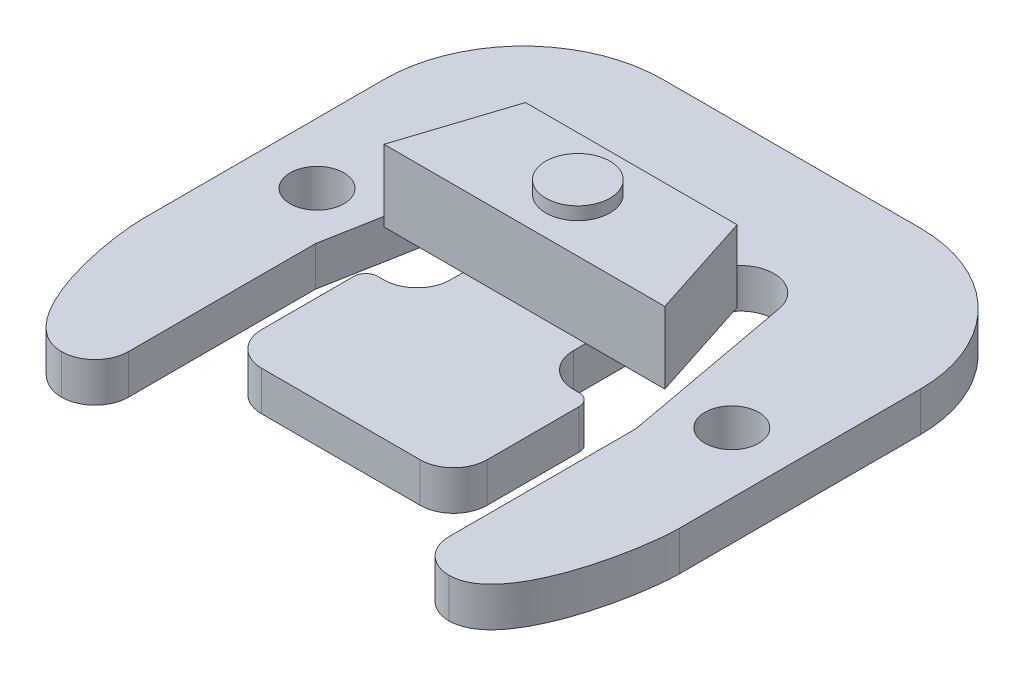
from build123d import *

# Parameters (mm, degrees)
SKETCH1_R           = 1.7018
BOSS_EXTRUDE1_DEPTH = 2.5019
BOSS_EXTRUDE2_DEPTH = 4.5339
SKETCH3_R           = 2.032
BOSS_EXTRUDE3_DEPTH = 0.8128
SKETCH4_R           = 1.77918252
BOSS_EXTRUDE4_DEPTH = 1.0033


with BuildPart() as part:
    # Sketch1 → Boss-Extrude1 (new body)
    with BuildSketch(Plane(origin=(0, 0, 0), x_dir=(1, 0, 0), z_dir=(0, 1, 0))):
        with BuildLine():
            Line((27.1272, -31.8389), (27.1272, -19.9898))
            Line((27.1272, -19.9898), (25.072658108, -8.860571344))
            ThreePointArc((25.072658108, -8.860571344), (22.793680926, -7.133528849), (20.8661, -9.2456))
            Line((20.8661, -9.2456), (20.8661, -17.7038))
            ThreePointArc((20.8661, -17.7038), (21.487297228, -19.203502772), (22.987, -19.8247))
            Line((22.987, -19.8247), (23.3553, -19.8247))
            ThreePointArc((23.3553, -19.8247), (23.894115367, -20.047884633), (24.1173, -20.5867))
            Line((24.1173, -20.5867), (24.1173, -26.416))
            ThreePointArc((24.1173, -26.416), (23.496102772, -27.915702772), (21.9964, -28.5369))
            Line((21.9964, -28.5369), (11.9634, -28.5369))
            ThreePointArc((11.9634, -28.5369), (10.463697228, -27.915702772), (9.8425, -26.416))
            Line((9.8425, -26.416), (9.8425, -20.5867))
            ThreePointArc((9.8425, -20.5867), (10.065684633, -20.047884633), (10.6045, -19.8247))
            Line((10.6045, -19.8247), (10.9728, -19.8247))
            ThreePointArc((10.9728, -19.8247), (12.472502772, -19.203502772), (13.0937, -17.7038))
            Line((13.0937, -17.7038), (13.0937, -9.2456))
            ThreePointArc((13.0937, -9.2456), (11.166119074, -7.133528849), (8.887141892, -8.860571344))
            Line((8.887141892, -8.860571344), (6.8326, -19.9898))
            Line((6.8326, -19.9898), (6.8326, -31.8389))
            ThreePointArc((6.8326, -31.8389), (6.211402772, -33.338602772), (4.7117, -33.9598))
            add(Edge.make_bspline(
                [(0, -24.0873616), (0, -26.517133331), (1.36922065, -33.9598), (4.7117, -33.9598)],
                knots=[0, 0, 0, 0, 1, 1, 1, 1], degree=3))
            Line((0, -24.0873616), (0, -8.8138))
            ThreePointArc((0, -8.8138), (2.581502252, -2.581502252), (8.8138, 0))
            Line((8.8138, 0), (25.146, 0))
            ThreePointArc((25.146, 0), (31.378297748, -2.581502252), (33.9598, -8.8138))
            Line((33.9598, -8.8138), (33.9598, -24.0873616))
            add(Edge.make_bspline(
                [(33.9598, -24.0873616), (33.9598, -26.517133331), (32.59057935, -33.9598), (29.2481, -33.9598)],
                knots=[0, 0, 0, 0, 1, 1, 1, 1], degree=3))
            ThreePointArc((29.2481, -33.9598), (27.748397228, -33.338602772), (27.1272, -31.8389))
        make_face()
        with Locations((30.1117, -16.9164)):
            Circle(SKETCH1_R, mode=Mode.SUBTRACT)
        with Locations((3.8481, -16.9164)):
            Circle(SKETCH1_R, mode=Mode.SUBTRACT)
    extrude(amount=BOSS_EXTRUDE1_DEPTH)

    # Sketch2 → Boss-Extrude2 (add)
    with BuildSketch(Plane(origin=(0, 2.5019, 0), x_dir=(1, 0, 0), z_dir=(0, 1, 0))):
        Polygon((8.0899, -16.9164), (25.8699, -16.9164), (23.67915, -10.1473), (10.28065, -10.1473), align=None)
    extrude(amount=BOSS_EXTRUDE2_DEPTH)

    # Sketch3 → Boss-Extrude3 (add)
    with BuildSketch(Plane(origin=(0, 7.0358, 0), x_dir=(-1, 0, 0), z_dir=(0, 1, 0))):
        with Locations((-16.9799, 13.53185)):
            Circle(SKETCH3_R)
    extrude(amount=BOSS_EXTRUDE3_DEPTH)

    # Sketch4 → Boss-Extrude4 (add)
    with BuildSketch(Plane.XZ):
        with Locations((13.894791914, 24.167570002)):
            Circle(SKETCH4_R)
        with Locations((20.065008086, 24.167570002)):
            Circle(SKETCH4_R)
    extrude(amount=BOSS_EXTRUDE4_DEPTH)


solid = part.part
